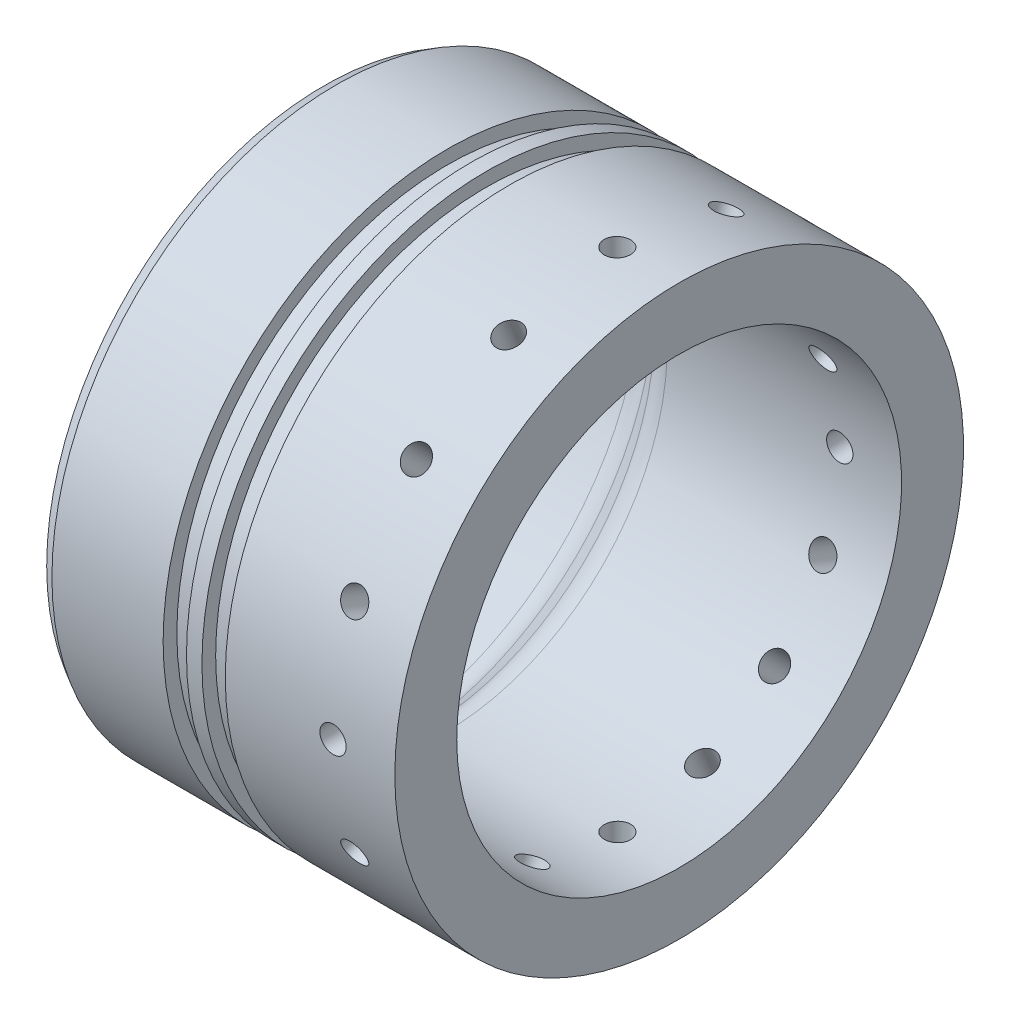
from build123d import *

# Parameters (mm, degrees)
TAP_DRILL_FOR_1_4_28_TAP1_D = 5.4102
TAP_PATTERN_COUNT           = 16
CHAMFER1_SIZE               = 2.54
CHAMFER1_SIZE2              = 1.466469684


with BuildPart() as part:
    # Sketch1 → Revolve1 (revolve)
    with BuildSketch(Plane.XY):
        with BuildLine():
            Line((-18.549937811, 3.2004), (-8.480193932, 3.2004))
            ThreePointArc((-8.480193932, 3.2004), (-6.050154137, 3.683764969), (-3.990065872, 5.060271939))
            Line((-3.990065872, 5.060271939), (1.815190249, 10.865528061))
            ThreePointArc((1.815190249, 10.865528061), (3.875278514, 12.242035031), (6.30531831, 12.7254))
            Line((6.30531831, 12.7254), (54.475062189, 12.7254))
            Line((54.475062189, 12.7254), (54.475062189, 0))
            Line((54.475062189, 0), (19.626262189, 0))
            Line((19.626262189, 0), (19.626262189, 2.8194))
            Line((19.626262189, 2.8194), (14.825662189, 2.8194))
            Line((14.825662189, 2.8194), (14.825662189, 0))
            Line((14.825662189, 0), (11.650662189, 0))
            Line((11.650662189, 0), (11.650662189, 2.8194))
            Line((11.650662189, 2.8194), (6.850062189, 2.8194))
            Line((6.850062189, 2.8194), (6.850062189, 0))
            Line((6.850062189, 0), (-18.549937811, 0))
            Line((-18.549937811, 0), (-18.549937811, 3.2004))
        make_face()
    revolve(axis=Axis((0, 58.4454, 0), (1, 0, 0)))

    # Tap Drill for 1/4-28 Tap1 (through all)
    with Locations(Plane(origin=(0, 0, -58.4454), x_dir=(-1, 0, 0), z_dir=(0, 0, -1))):
        with Locations((-41.775062189, 58.4454)):
            tap_drill_for_1_4_28_tap1 = Hole(TAP_DRILL_FOR_1_4_28_TAP1_D / 2)

    # Tap Pattern: Tap Drill for 1/4-28 Tap1 ×16 about axis
    tap_pattern_axis = Axis((0, 58.4454, 0), (1, 0, 0))
    for i in range(1, TAP_PATTERN_COUNT):
        add(tap_drill_for_1_4_28_tap1.rotate(tap_pattern_axis, i * 360 / TAP_PATTERN_COUNT), mode=Mode.SUBTRACT)

    # Chamfer1
    chamfer1_edges = [part.edges().sort_by_distance(p)[0] for p in [
        (-18.549937811, 116.8908, 0),
    ]]
    chamfer1_side = [part.faces().sort_by_distance(p)[0] for p in [
        (-5.849937811, 116.8908, 0),
    ]]
    chamfer(chamfer1_edges, length=CHAMFER1_SIZE, length2=CHAMFER1_SIZE2, reference=chamfer1_side[0])


solid = part.part
